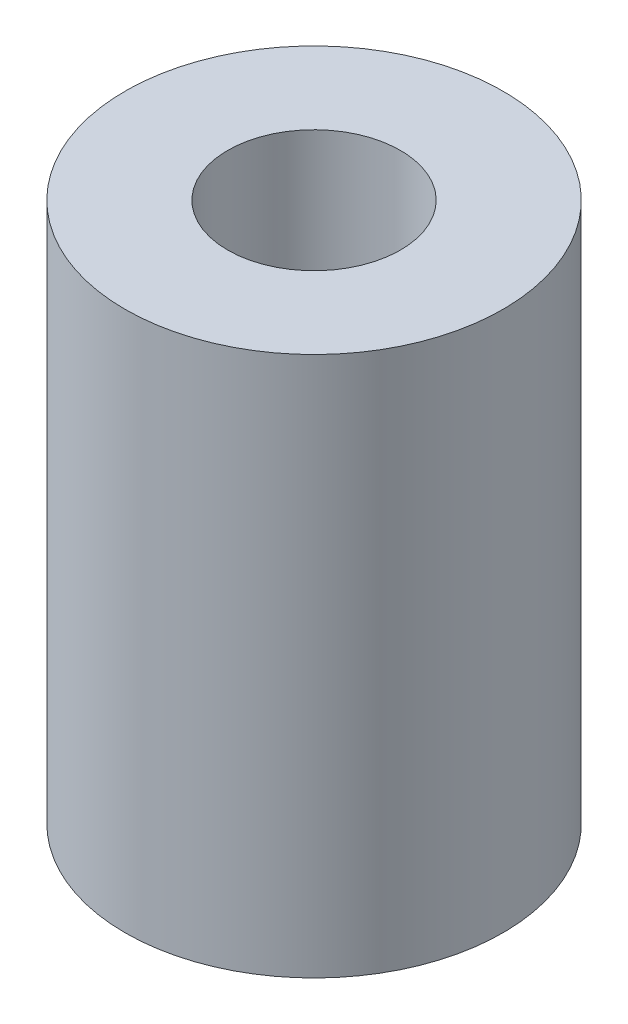
from build123d import *

# Parameters (mm, degrees)
SKETCH1_R           = 3.5
SKETCH1_R_2         = 1.6
BOSS_EXTRUDE1_DEPTH = 5


with BuildPart() as part:
    # Sketch1 → Boss-Extrude1 (new body, symmetric)
    with BuildSketch(Plane(origin=(0, 0, 0), x_dir=(1, 0, 0), z_dir=(0, 1, 0))):
        Circle(SKETCH1_R)
        Circle(SKETCH1_R_2, mode=Mode.SUBTRACT)
    extrude(amount=BOSS_EXTRUDE1_DEPTH, both=True)


solid = part.part
